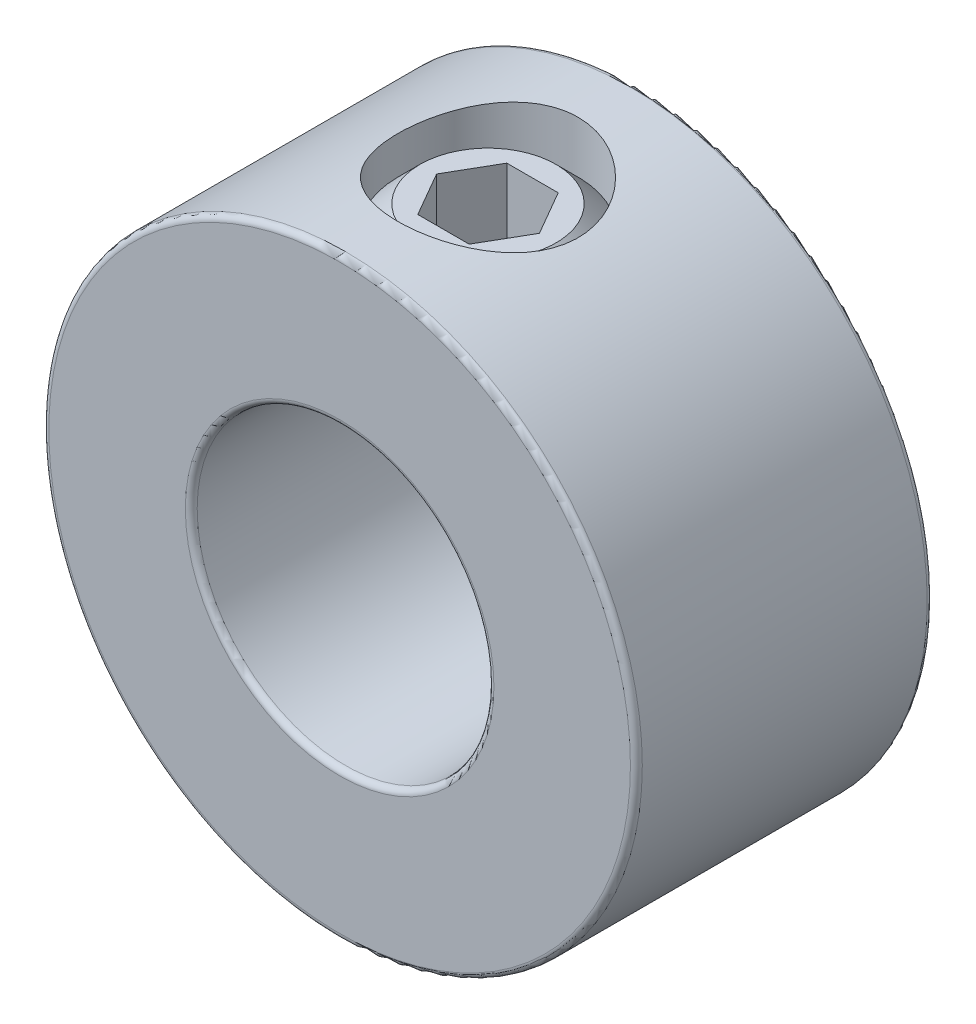
from build123d import *

# Parameters (mm, degrees)
SKETCH1_R          = 7.9375
SKETCH1_R_2        = 3.96875
EXTRUDE1_DEPTH     = 3.96875
SKETCH2_R          = 2.413
CUT_EXTRUDE1_DEPTH = 8.9375
FILLET1_R          = 0.15875
CUT_EXTRUDE2_DEPTH = 2.38125


with BuildPart() as part:
    # Sketch1 → Extrude1 (new body, symmetric)
    with BuildSketch(Plane.XY):
        Circle(SKETCH1_R)
        Circle(SKETCH1_R_2, mode=Mode.SUBTRACT)
    extrude(amount=EXTRUDE1_DEPTH, both=True)

    # Sketch2 → Cut-Extrude1 (cut, through all)
    with BuildSketch(Plane(origin=(41.275, 0, 0), x_dir=(0, 0, -1), z_dir=(0, -1, 0))):
        with Locations((0, -41.275)):
            Circle(SKETCH2_R)
    extrude(amount=-CUT_EXTRUDE1_DEPTH, mode=Mode.SUBTRACT)

    # Fillet1
    fillet1_edges = [part.edges().sort_by_distance(p)[0] for p in [
        (-7.9375, 0, -3.96875),
        (-7.9375, 0, 3.96875),
        (-3.96875, 0, -3.96875),
        (-3.96875, 0, 3.96875),
    ]]
    fillet(fillet1_edges, radius=FILLET1_R)


with BuildPart() as body_2:
    # Sketch3 → Revolve1 (revolve)
    with BuildSketch(Plane.XY):
        Polygon((-1.819751616, 3.96875), (-0.71189806, 3.96875), (0, 4.68064806), (0, 7.14375), (-1.819751616, 7.14375), (-2.413, 6.550501616), (-2.413, 4.561998384), align=None)
    revolve(axis=Axis((0, 3.96875, 0), (0, -1, 0)))

    # Sketch4 → Cut-Extrude2 (cut)
    with BuildSketch(Plane(origin=(3.3734375, 7.14375, 0), x_dir=(0, 0, -1), z_dir=(0, -1, 0))):
        Polygon((0, -1.998622171), (-1.190625, -2.686029836), (-1.190625, -4.060845164), (0, -4.748252829), (1.190625, -4.060845164), (1.190625, -2.686029836), align=None)
    extrude(amount=CUT_EXTRUDE2_DEPTH, mode=Mode.SUBTRACT)


solid = Compound([part.part, body_2.part])
